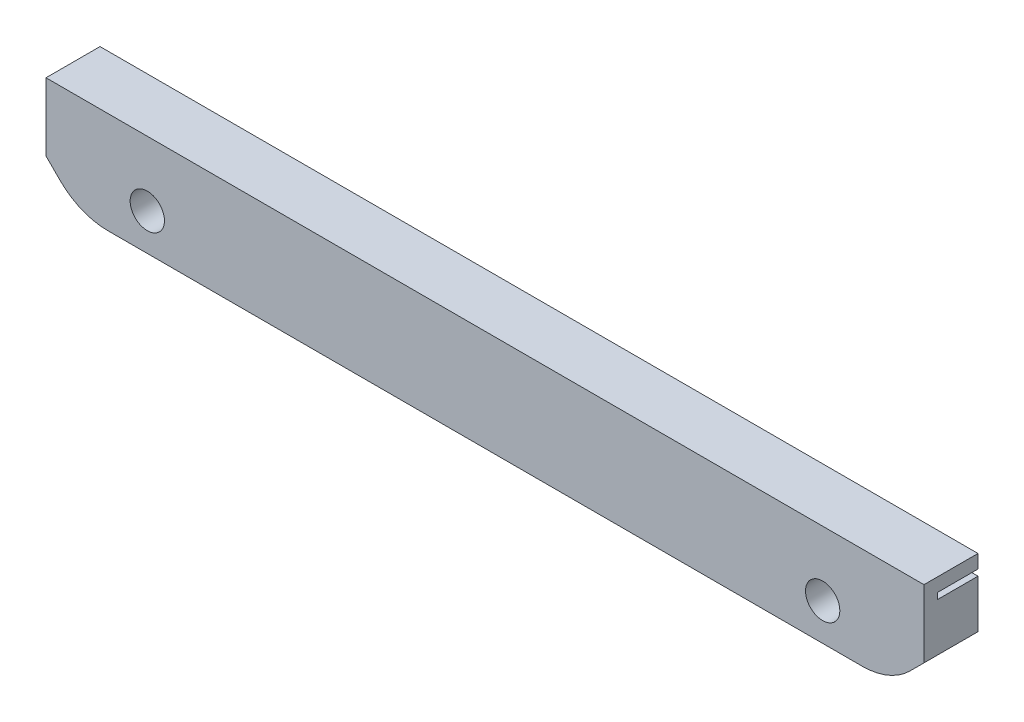
from build123d import *

# Parameters (mm, degrees)
SKETCH2_W           = 130
SKETCH2_H           = 15.033728121
SKETCH2_R           = 2.54
BOSS_EXTRUDE1_DEPTH = 6
CUT_EXTRUDE1_DEPTH  = 7
SKETCH5_W           = 130
SKETCH5_H           = 15.033728121
SKETCH5_R           = 2.54
BOSS_EXTRUDE2_DEPTH = 2
CHAMFER1_SIZE       = 5
FILLET1_R           = 10


with BuildPart() as part:
    # Sketch2 → Boss-Extrude1 (new body)
    with BuildSketch(Plane.XY):
        with Locations((-50, 62.31313594)):
            Rectangle(SKETCH2_W, SKETCH2_H)
        with Locations((-100, 60.26)):
            Circle(SKETCH2_R, mode=Mode.SUBTRACT)
        with Locations((0, 60.26)):
            Circle(SKETCH2_R, mode=Mode.SUBTRACT)
    extrude(amount=BOSS_EXTRUDE1_DEPTH)

    # Sketch3 → Cut-Extrude1 (cut, through all)
    with BuildSketch(Plane.XY.offset(6)):
        Polygon((-59.528536352, 67.83), (-59.528536352, 59.304721352), (-61.06183, 59.304721352), (-61.06183, 60.303576352), (-60.43953, 60.303576352), (-60.43953, 61.302431352), (-61.06183, 61.302431352), (-61.06183, 62.301286352), (-60.43953, 62.301286352), (-60.43953, 63.300141352), (-61.06183, 63.300141352), (-61.06183, 64.298996352), (-60.43953, 64.298996352), (-60.43953, 65.297851352), (-61.06183, 65.297851352), (-61.06183, 66.296706352), (-62.060685, 66.296706352), (-62.060685, 66.919006352), (-63.05954, 66.919006352), (-63.05954, 66.296706352), (-64.058395, 66.296706352), (-64.058395, 66.919006352), (-65.05725, 66.919006352), (-65.05725, 66.296706352), (-66.056105, 66.296706352), (-66.056105, 66.919006352), (-67.05496, 66.919006352), (-67.05496, 66.296706352), (-68.053815, 66.296706352), (-68.053815, 66.919006352), (-69.05267, 66.919006352), (-69.05267, 66.296706352), (-70.051525, 66.296706352), (-70.051525, 66.919006352), (-71.05038, 66.919006352), (-71.05038, 66.296706352), (-72.049235, 66.296706352), (-72.049235, 66.919006352), (-73.04809, 66.919006352), (-73.04809, 66.296706352), (-74.046945, 66.296706352), (-74.046945, 66.919006352), (-75.0458, 66.919006352), (-75.0458, 66.296706352), (-76.044655, 66.296706352), (-76.044655, 66.919006352), (-77.04351, 66.919006352), (-77.04351, 66.296706352), (-78.042365, 66.296706352), (-78.042365, 66.919006352), (-79.04122, 66.919006352), (-79.04122, 66.296706352), (-80.040075, 66.296706352), (-80.040075, 66.919006352), (-81.03893, 66.919006352), (-81.03893, 66.296706352), (-82.037785, 66.296706352), (-82.037785, 66.919006352), (-83.03664, 66.919006352), (-83.03664, 66.296706352), (-84.035495, 66.296706352), (-84.035495, 66.919006352), (-85.03435, 66.919006352), (-85.03435, 66.296706352), (-86.033205, 66.296706352), (-86.033205, 66.919006352), (-87.03206, 66.919006352), (-87.03206, 66.296706352), (-88.030915, 66.296706352), (-88.030915, 66.919006352), (-89.02977, 66.919006352), (-89.02977, 66.296706352), (-90.028625, 66.296706352), (-90.028625, 66.919006352), (-91.02748, 66.919006352), (-91.02748, 66.296706352), (-92.026335, 66.296706352), (-92.026335, 66.919006352), (-93.02519, 66.919006352), (-93.02519, 66.296706352), (-94.024045, 66.296706352), (-94.024045, 66.919006352), (-95.0229, 66.919006352), (-95.0229, 66.296706352), (-96.021755, 66.296706352), (-96.021755, 66.919006352), (-97.02061, 66.919006352), (-97.02061, 66.296706352), (-98.019465, 66.296706352), (-98.019465, 66.919006352), (-99.01832, 66.919006352), (-99.01832, 66.296706352), (-100.017175, 66.296706352), (-100.017175, 66.919006352), (-101.01603, 66.919006352), (-101.01603, 66.296706352), (-102.014885, 66.296706352), (-102.014885, 66.919006352), (-103.01374, 66.919006352), (-103.01374, 66.296706352), (-104.012595, 66.296706352), (-104.012595, 66.919006352), (-105.01145, 66.919006352), (-105.01145, 66.296706352), (-106.010305, 66.296706352), (-106.010305, 66.919006352), (-107.00916, 66.919006352), (-107.00916, 66.296706352), (-108.008015, 66.296706352), (-108.008015, 66.919006352), (-109.00687, 66.919006352), (-109.00687, 66.296706352), (-110.005725, 66.296706352), (-110.005725, 66.919006352), (-111.00458, 66.919006352), (-111.00458, 66.296706352), (-112.003435, 66.296706352), (-112.003435, 66.919006352), (-113.00229, 66.919006352), (-113.00229, 66.296706352), (-114.001145, 66.296706352), (-114.001145, 66.919006352), (-115, 66.919006352), (-115, 67.83), align=None)
    cut_extrude1 = extrude(amount=-CUT_EXTRUDE1_DEPTH, mode=Mode.SUBTRACT)

    # Mirror1: Cut-Extrude1 across plane
    add(cut_extrude1.mirror(Plane(origin=(-50, 0, 0), x_dir=(0, 0, 1), z_dir=(1, 0, 0))), mode=Mode.SUBTRACT)

    # Sketch5 → Boss-Extrude2 (add)
    with BuildSketch(Plane.XY.offset(6)):
        with Locations((-50, 62.31313594)):
            Rectangle(SKETCH5_W, SKETCH5_H)
        with Locations((-100, 60.26)):
            Circle(SKETCH5_R, mode=Mode.SUBTRACT)
        with Locations((0, 60.26)):
            Circle(SKETCH5_R, mode=Mode.SUBTRACT)
    extrude(amount=BOSS_EXTRUDE2_DEPTH)

    # Chamfer1
    chamfer1_edges = [part.edges().sort_by_distance(p)[0] for p in [
        (15, 54.796271879, 4),
        (-115, 54.796271879, 4),
    ]]
    chamfer(chamfer1_edges, length=CHAMFER1_SIZE)

    # Fillet1
    fillet1_edges = [part.edges().sort_by_distance(p)[0] for p in [
        (-110, 54.796271879, 4),
        (10, 54.796271879, 4),
    ]]
    fillet(fillet1_edges, radius=FILLET1_R)


solid = part.part
